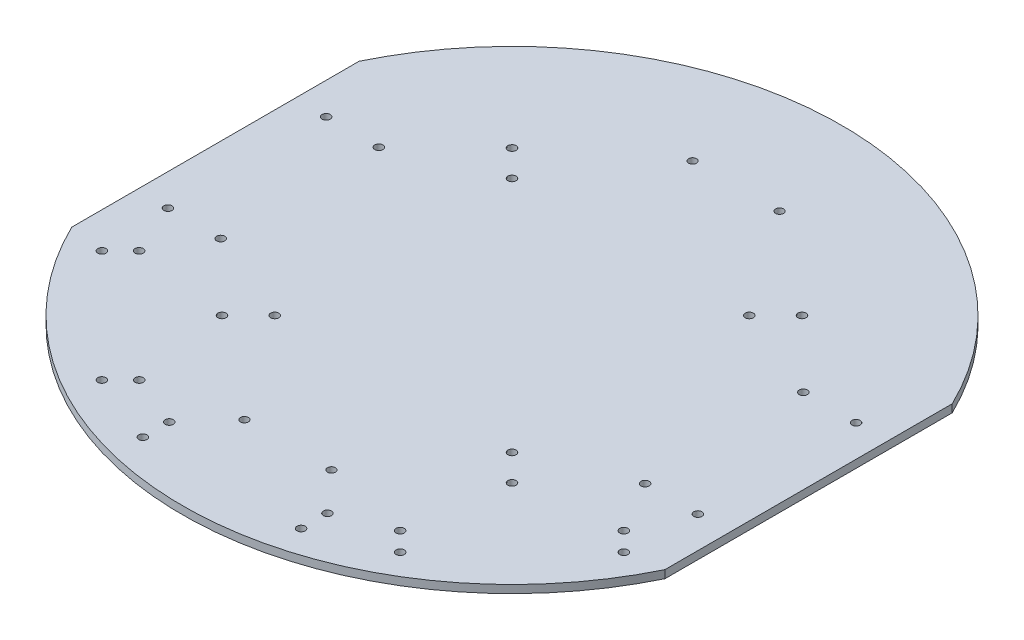
from build123d import *

# Parameters (mm, degrees)
SKETCH1_R           = 1.55
BOSS_EXTRUDE1_DEPTH = 3
SKETCH2_R           = 1.5
CUT_EXTRUDE1_DEPTH  = 4
SKETCH3_R           = 1.55
CUT_EXTRUDE2_DEPTH  = 4
SKETCH4_R           = 1.55
CUT_EXTRUDE3_DEPTH  = 4
CIRPATTERN1_COUNT   = 2
CIRPATTERN1_ANGLE   = 45
CIRPATTERN2_COUNT   = 2
CIRPATTERN2_ANGLE   = 45


with BuildPart() as part:
    # Sketch1 → Boss-Extrude1 (new body)
    with BuildSketch(Plane(origin=(0, 0, 0), x_dir=(1, 0, 0), z_dir=(0, 1, 0))):
        with BuildLine():
            ThreePointArc((112.5, 54.486236794), (0, 125), (-112.5, 54.486236794))
            Line((-112.5, 54.486236794), (-112.5, -54.486236794))
            ThreePointArc((-112.5, -54.486236794), (0, -125), (112.5, -54.486236794))
            Line((112.5, -54.486236794), (112.5, 54.486236794))
        make_face()
        with Locations((-55, -55)):
            Circle(SKETCH1_R, mode=Mode.SUBTRACT)
        with Locations((-45, -45)):
            Circle(SKETCH1_R, mode=Mode.SUBTRACT)
        with Locations((55, -55)):
            Circle(SKETCH1_R, mode=Mode.SUBTRACT)
        with Locations((45, -45)):
            Circle(SKETCH1_R, mode=Mode.SUBTRACT)
        with Locations((-45, 45)):
            Circle(SKETCH1_R, mode=Mode.SUBTRACT)
        with Locations((-55, 55)):
            Circle(SKETCH1_R, mode=Mode.SUBTRACT)
        with Locations((45, 45)):
            Circle(SKETCH1_R, mode=Mode.SUBTRACT)
        with Locations((55, 55)):
            Circle(SKETCH1_R, mode=Mode.SUBTRACT)
    extrude(amount=BOSS_EXTRUDE1_DEPTH)

    # Sketch2 → Cut-Extrude1 (cut, through all)
    with BuildSketch(Plane(origin=(0, 3, 0), x_dir=(1, 0, 0), z_dir=(0, 1, 0))):
        with Locations((-16.5, 85)):
            Circle(SKETCH2_R)
        with Locations((16.5, 85)):
            Circle(SKETCH2_R)
        with Locations((16.5, -85)):
            Circle(SKETCH2_R)
        with Locations((-16.5, -85)):
            Circle(SKETCH2_R)
    extrude(amount=-CUT_EXTRUDE1_DEPTH, mode=Mode.SUBTRACT)

    # Sketch3 → Cut-Extrude2 (cut, through all)
    with BuildSketch(Plane(origin=(0, 3, 0), x_dir=(1, 0, 0), z_dir=(0, 1, 0))):
        with Locations((-100.5, -30)):
            Circle(SKETCH3_R)
        with Locations((-80.5, -30)):
            Circle(SKETCH3_R)
        with Locations((-80.5, 30)):
            Circle(SKETCH3_R)
        with Locations((-100.5, 30)):
            Circle(SKETCH3_R)
        with Locations((100.5, 30)):
            Circle(SKETCH3_R)
        with Locations((80.5, 30)):
            Circle(SKETCH3_R)
        with Locations((100.5, -30)):
            Circle(SKETCH3_R)
        with Locations((80.5, -30)):
            Circle(SKETCH3_R)
    extrude(amount=-CUT_EXTRUDE2_DEPTH, mode=Mode.SUBTRACT)

    # Sketch4 → Cut-Extrude3 (cut, through all)
    with BuildSketch(Plane(origin=(0, 3, 0), x_dir=(1, 0, 0), z_dir=(0, 1, 0))):
        with Locations((-30, -110)):
            Circle(SKETCH4_R)
        with Locations((-30, -100)):
            Circle(SKETCH4_R)
        with Locations((30, -110)):
            Circle(SKETCH4_R)
        with Locations((30, -100)):
            Circle(SKETCH4_R)
    cut_extrude3 = extrude(amount=-CUT_EXTRUDE3_DEPTH, mode=Mode.SUBTRACT)

    # CirPattern1: Cut-Extrude3 ×2 about axis
    cirpattern1_axis = Axis((0, 0, 0), (0, 1, 0))
    for i in range(1, CIRPATTERN1_COUNT):
        add(cut_extrude3.rotate(cirpattern1_axis, i * CIRPATTERN1_ANGLE / (CIRPATTERN1_COUNT - 1)), mode=Mode.SUBTRACT)

    # CirPattern2: Cut-Extrude3 ×2 about axis
    cirpattern2_axis = Axis((0, 0, 0), (0, -1, 0))
    for i in range(1, CIRPATTERN2_COUNT):
        add(cut_extrude3.rotate(cirpattern2_axis, i * CIRPATTERN2_ANGLE / (CIRPATTERN2_COUNT - 1)), mode=Mode.SUBTRACT)


solid = part.part
